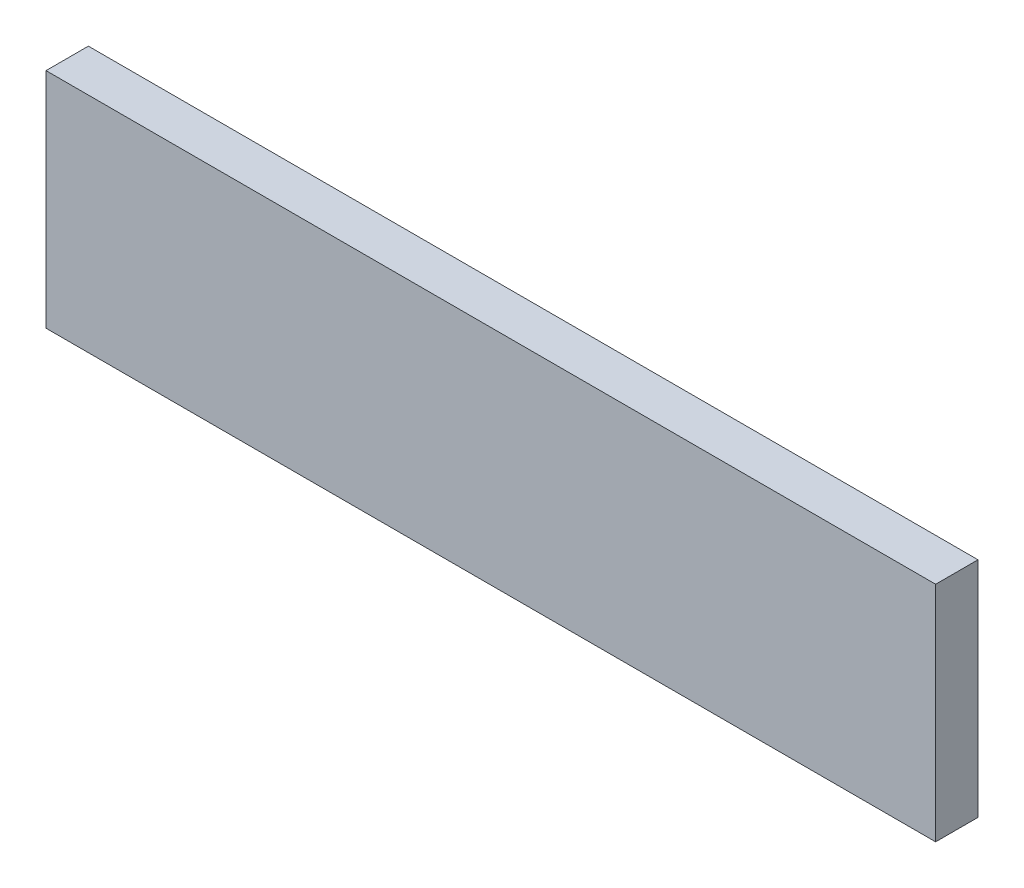
from build123d import *

# Parameters (mm, degrees)
SKETCH1_W           = 80.01
SKETCH1_H           = 20.066
BOSS_EXTRUDE1_DEPTH = 3.81


with BuildPart() as part:
    # Sketch1 → Boss-Extrude1 (new body)
    with BuildSketch(Plane.XY):
        Rectangle(SKETCH1_W, SKETCH1_H)
    extrude(amount=BOSS_EXTRUDE1_DEPTH)


solid = part.part
